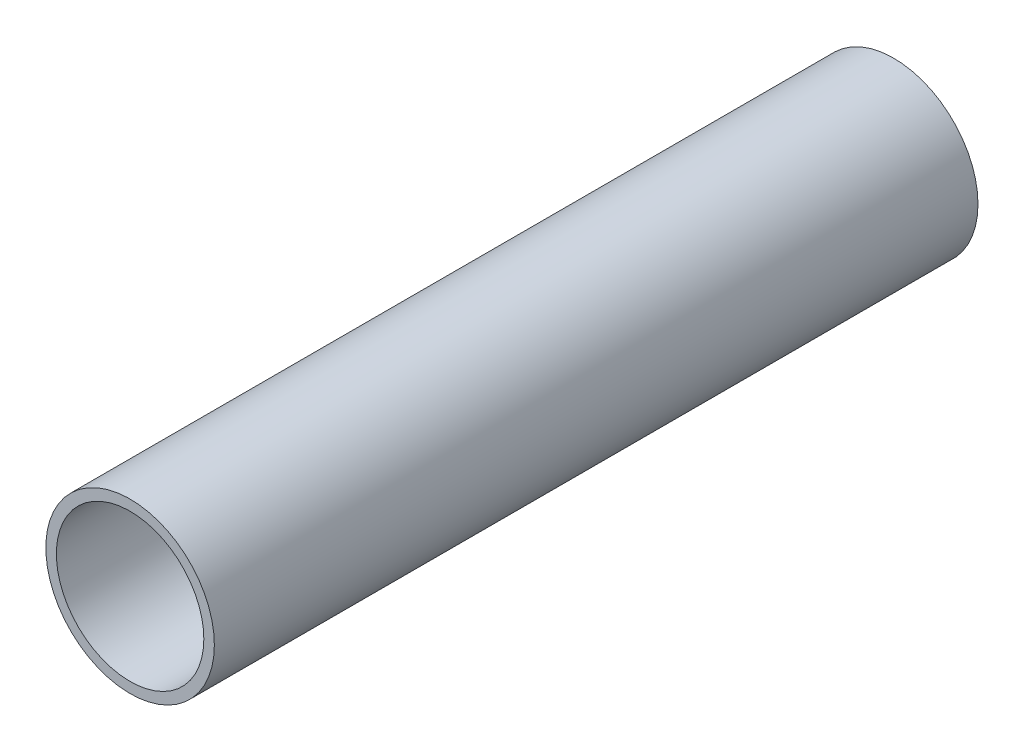
from build123d import *

# Parameters (mm, degrees)
SKETCH1_R           = 16
SKETCH1_R_2         = 14
BOSS_EXTRUDE1_DEPTH = 145


with BuildPart() as part:
    # Sketch1 → Boss-Extrude1 (new body)
    with BuildSketch(Plane.XY):
        Circle(SKETCH1_R)
        Circle(SKETCH1_R_2, mode=Mode.SUBTRACT)
    extrude(amount=BOSS_EXTRUDE1_DEPTH)


solid = part.part
